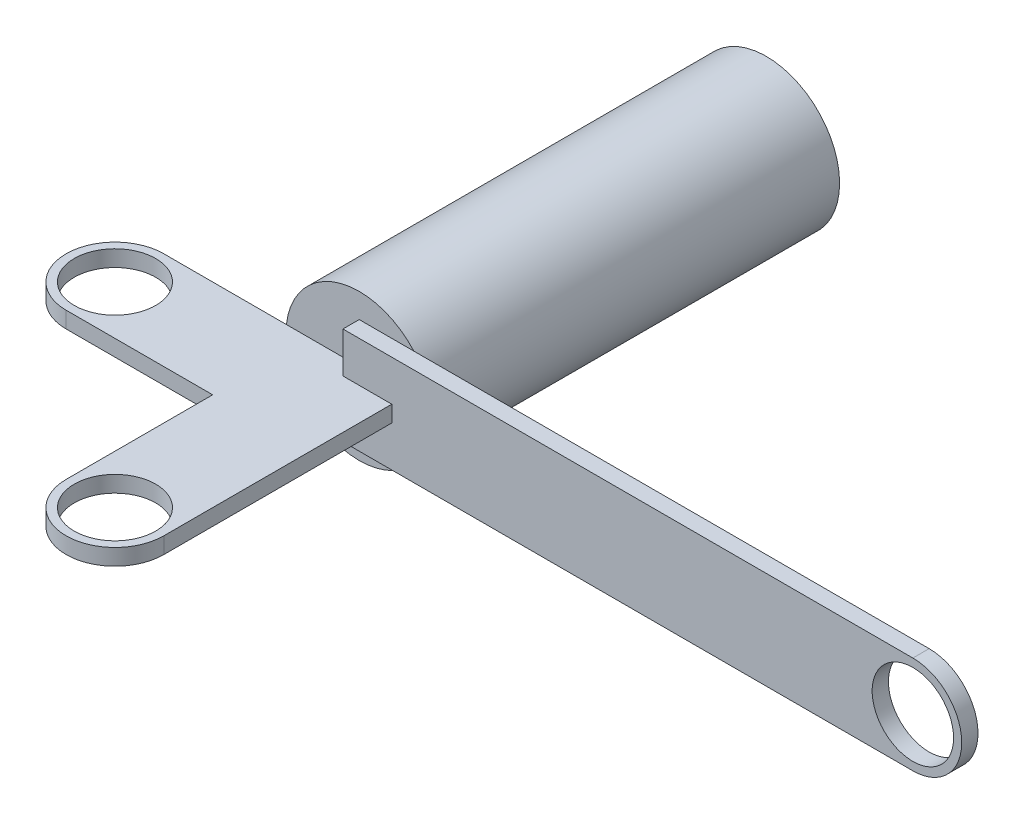
from build123d import *

# Parameters (mm, degrees)
SKETCH1_R           = 9
BOSS_EXTRUDE1_DEPTH = 50
SKETCH2_R           = 5
BOSS_EXTRUDE2_DEPTH = 2
SKETCH4_W           = 12
SKETCH4_H           = 12
SKETCH4_R           = 5
BOSS_EXTRUDE3_DEPTH = 1


with BuildPart() as part:
    # Sketch1 → Boss-Extrude1 (new body)
    with BuildSketch(Plane.XY):
        Circle(SKETCH1_R)
    extrude(amount=-BOSS_EXTRUDE1_DEPTH)



with BuildPart() as body_2:
    # Sketch2 → Boss-Extrude2 (new body)
    with BuildSketch(Plane.XY):
        with BuildLine():
            Line((0, 0), (0, 6))
            Line((0, 6), (70, 6))
            ThreePointArc((70, 6), (76, 0), (70, -6))
            Line((70, -6), (0, -6))
            Line((0, -6), (0, 0))
        make_face()
        with Locations((70, 0)):
            Circle(SKETCH2_R, mode=Mode.SUBTRACT)
    extrude(amount=BOSS_EXTRUDE2_DEPTH)


with BuildPart() as part_1:
    add(part.part)

    add(body_2.part)  # Boss-Extrude3 merges body 2
    # Sketch4 → Boss-Extrude3 (add, symmetric)
    with BuildSketch(Plane(origin=(0, 0, 0), x_dir=(1, 0, 0), z_dir=(0, 1, 0))):
        with Locations((0, -6)):
            Rectangle(SKETCH4_W, SKETCH4_H)
        with BuildLine():
            Line((-6, -12), (-6, 0))
            Line((-6, 0), (-24, 0))
            ThreePointArc((-24, 0), (-30, -6), (-24, -12))
            Line((-24, -12), (-6, -12))
        make_face()
        with Locations((-24, -6)):
            Circle(SKETCH4_R, mode=Mode.SUBTRACT)
        with BuildLine():
            Line((6, -12), (-6, -12))
            Line((-6, -12), (-6, -30))
            ThreePointArc((-6, -30), (0, -36), (6, -30))
            Line((6, -30), (6, -12))
        make_face()
        with Locations((0, -30)):
            Circle(SKETCH4_R, mode=Mode.SUBTRACT)
    extrude(amount=BOSS_EXTRUDE3_DEPTH, both=True)


solid = part_1.part
